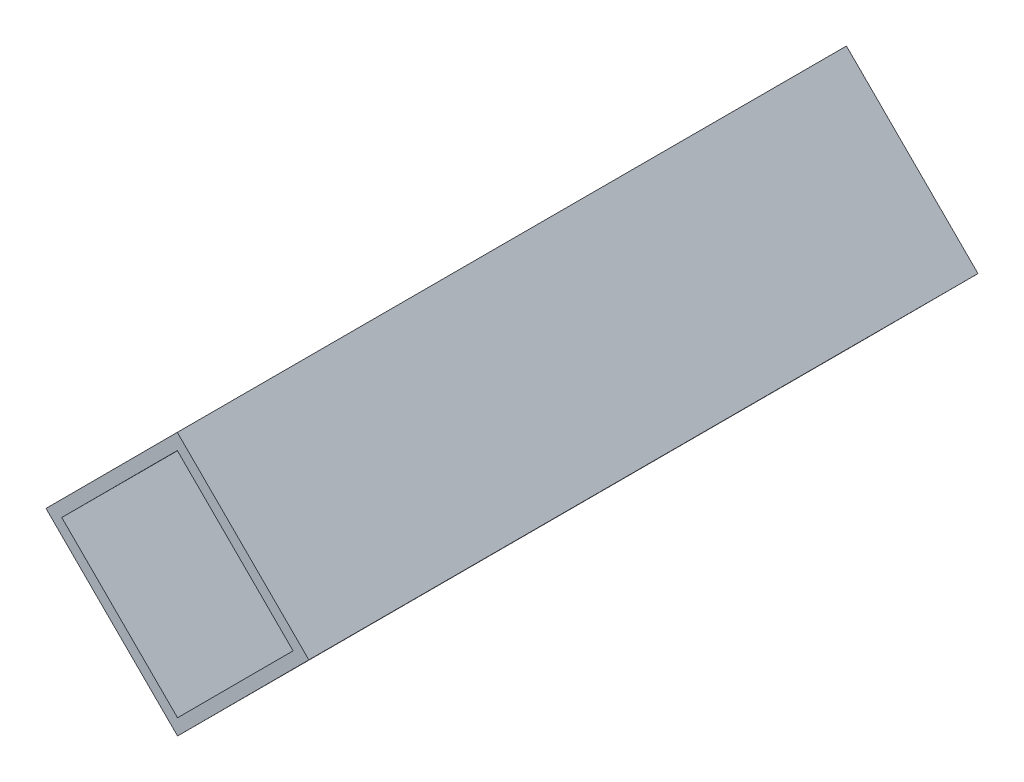
from build123d import *

# Parameters (mm, degrees)
EXTRUDE_1_DEPTH = 90


with BuildPart() as part:
    # 草圖1 → 填料-伸長1 (new body)
    with BuildSketch(Plane.XY):
        Polygon((0, 0), (17.69379362, -17.661530719), (0.032262901, -35.355324339), (-17.661530719, -17.69379362), align=None)
        Polygon((0.001935774, -2.12131946), (-15.540211259, -17.691857846), (0.030327127, -33.234004879), (15.57247416, -17.663466493), align=None, mode=Mode.SUBTRACT)
    extrude(amount=EXTRUDE_1_DEPTH)


solid = part.part
